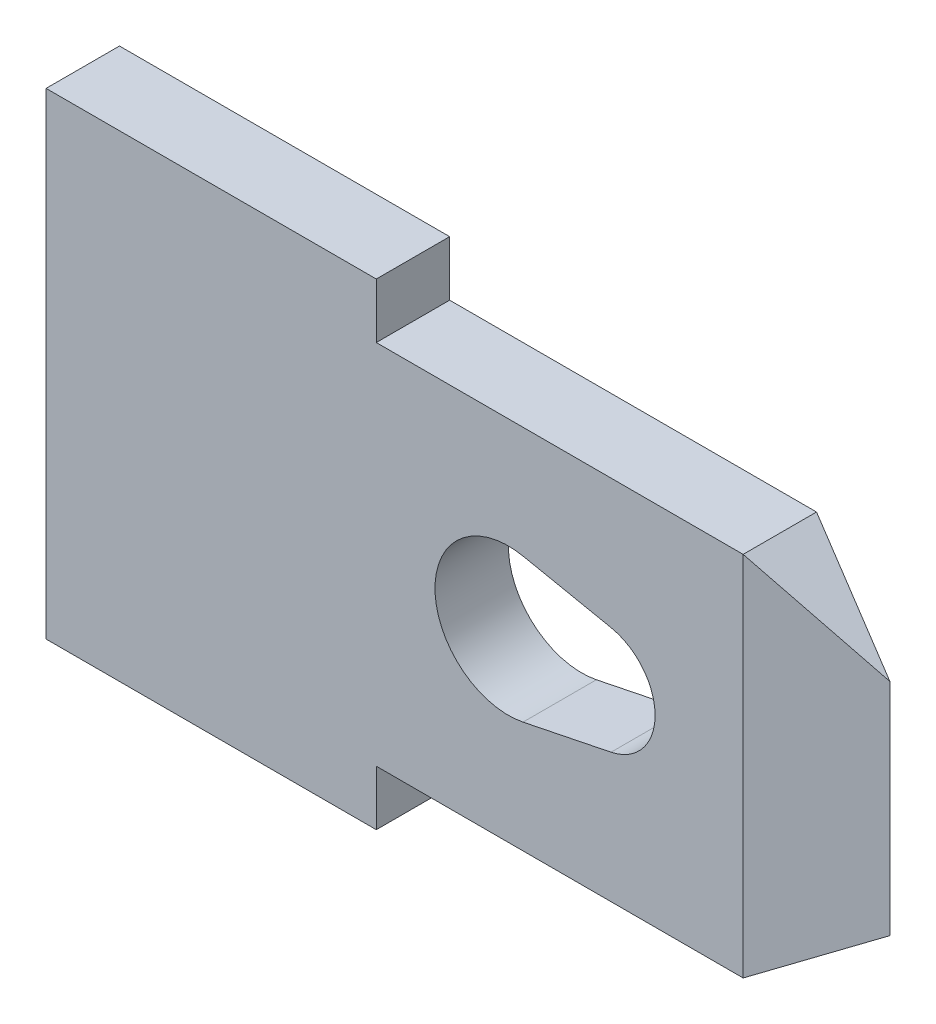
from build123d import *

# Parameters (mm, degrees)
DODANIE_WYCI_GNI_CIE1_DEPTH = 1
WYTNIJ_WYCI_GNI_CIE1_REACH  = 3
WYTNIJ_WYCI_GNI_CIE2_REACH  = 7.75


with BuildPart() as part:
    # Szkic1 → Dodanie-wyciągnięcie1 (new body)
    with BuildSketch(Plane.XY):
        Polygon((0, -3.25), (0, 3.25), (4.5, 3.25), (4.5, 2.5), (9.5, 2.5), (11, 1.5), (11, -1.5), (9.5, -2.5), (4.5, -2.5), (4.5, -3.25), align=None)
    extrude(amount=DODANIE_WYCI_GNI_CIE1_DEPTH)

    # Szkic2 → Wytnij-wyciągnięcie1 (cut, up to next)
    with BuildSketch(Plane.XY.offset(1), mode=Mode.PRIVATE) as wytnij_wyci_gni_cie1_sk1:
        with BuildLine():
            Line((6.5, 0.979795897), (7.7, 0.734846923))
            ThreePointArc((7.7, 0.734846923), (8.3, 0), (7.7, -0.734846923))
            Line((7.7, -0.734846923), (6.5, -0.979795897))
            ThreePointArc((6.5, -0.979795897), (5.3, 0), (6.5, 0.979795897))
        make_face()
    wytnij_wyci_gni_cie1_tool1 = extrude(wytnij_wyci_gni_cie1_sk1.sketch, amount=-WYTNIJ_WYCI_GNI_CIE1_REACH, mode=Mode.PRIVATE) & part.part
    add(wytnij_wyci_gni_cie1_tool1.solids().sort_by_distance((6.737463, 0, 1))[0], mode=Mode.SUBTRACT)

    # Szkic3 → Wytnij-wyciągnięcie2 (cut, up to next)
    with BuildSketch(Plane(origin=(0, 2.5, 0), x_dir=(1, 0, 0), z_dir=(0, 1, 0)), mode=Mode.PRIVATE) as wytnij_wyci_gni_cie2_sk1:
        Polygon((11, -1), (11, -0.5), (9.5, -1), align=None)
    wytnij_wyci_gni_cie2_tool1 = extrude(wytnij_wyci_gni_cie2_sk1.sketch, amount=-WYTNIJ_WYCI_GNI_CIE2_REACH, mode=Mode.PRIVATE) & part.part
    add(wytnij_wyci_gni_cie2_tool1.solids().sort_by_distance((10.5, 2.5, 0.833333))[0], mode=Mode.SUBTRACT)
    # Szkic3 → Wytnij-wyciągnięcie2 (cut, up to next)
    with BuildSketch(Plane(origin=(0, 2.5, 0), x_dir=(1, 0, 0), z_dir=(0, 1, 0)), mode=Mode.PRIVATE) as wytnij_wyci_gni_cie2_sk2:
        Polygon((9.5, 0), (11, -0.5), (11, 0), align=None)
    wytnij_wyci_gni_cie2_tool2 = extrude(wytnij_wyci_gni_cie2_sk2.sketch, amount=-WYTNIJ_WYCI_GNI_CIE2_REACH, mode=Mode.PRIVATE) & part.part
    add(wytnij_wyci_gni_cie2_tool2.solids().sort_by_distance((10.5, 2.5, 0.166667))[0], mode=Mode.SUBTRACT)


solid = part.part
